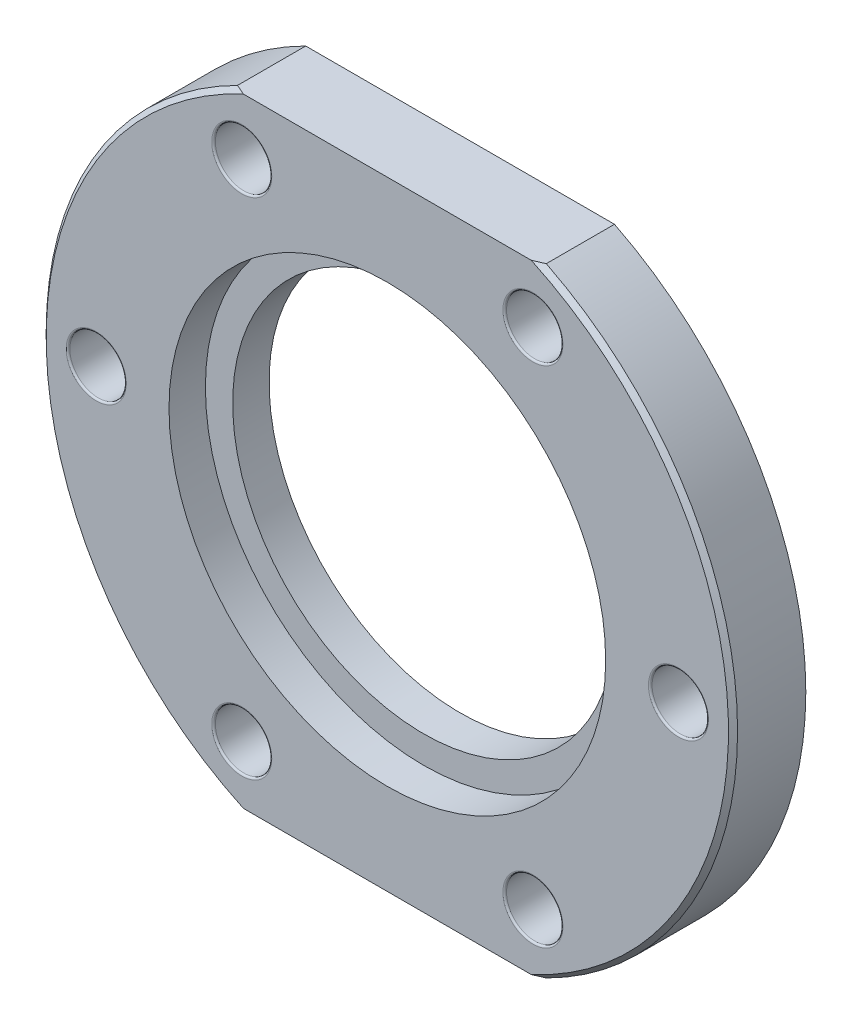
from build123d import *

# Parameters (mm, degrees)
SKETCH1_R               = 19
BOSS_EXTRUDE1_DEPTH     = 4
CUT_EXTRUDE1_DEPTH      = 1
CUT_EXTRUDE1_DEPTH_BACK = 5
SKETCH3_R               = 1.55
CUT_EXTRUDE2_DEPTH      = 1
CUT_EXTRUDE2_DEPTH_BACK = 5
FILLET1_R               = 0.1
SKETCH4_R               = 12
CUT_EXTRUDE3_DEPTH      = 1
CUT_EXTRUDE3_DEPTH_BACK = 2
SKETCH5_R               = 10.5
CUT_EXTRUDE4_DEPTH      = 2
CHAMFER2_SIZE           = 0.25


with BuildPart() as part:
    # Sketch1 → Boss-Extrude1 (new body)
    with BuildSketch(Plane.XY):
        Circle(SKETCH1_R)
    extrude(amount=BOSS_EXTRUDE1_DEPTH)

    # Sketch2 → Cut-Extrude1 (cut, two sides)
    with BuildSketch(Plane.XY.offset(4)) as cut_extrude1_sk:
        with BuildLine():
            Line((8.485281374, -17), (-8.485281374, -17))
            ThreePointArc((-8.485281374, -17), (0, -19), (8.485281374, -17))
        make_face()
        with BuildLine():
            ThreePointArc((-6.7e-08, 19), (-4.358898976, 18.493242001), (-8.485281374, 17))
            Line((-8.485281374, 17), (8.485281374, 17))
            ThreePointArc((8.485281374, 17), (4.358898911, 18.493242017), (-6.7e-08, 19))
        make_face()
    extrude(amount=CUT_EXTRUDE1_DEPTH, mode=Mode.SUBTRACT)
    extrude(cut_extrude1_sk.sketch, amount=-CUT_EXTRUDE1_DEPTH_BACK, mode=Mode.SUBTRACT)

    # Sketch3 → Cut-Extrude2 (cut, two sides)
    with BuildSketch(Plane.XY.offset(4)) as cut_extrude2_sk:
        with Locations((-16, 0)):
            Circle(SKETCH3_R)
        with Locations((-8, 13.856406461)):
            Circle(SKETCH3_R)
        with Locations((8, 13.856406461)):
            Circle(SKETCH3_R)
        with Locations((16, 0)):
            Circle(SKETCH3_R)
        with Locations((8, -13.856406461)):
            Circle(SKETCH3_R)
        with Locations((-8, -13.856406461)):
            Circle(SKETCH3_R)
    extrude(amount=CUT_EXTRUDE2_DEPTH, mode=Mode.SUBTRACT)
    extrude(cut_extrude2_sk.sketch, amount=-CUT_EXTRUDE2_DEPTH_BACK, mode=Mode.SUBTRACT)

    # Fillet1
    fillet1_edges = [part.edges().sort_by_distance(p)[0] for p in [
        (-17.55, 0, 4),
        (-17.55, 0, 0),
        (-9.55, -13.856406461, 4),
        (-9.55, -13.856406461, 0),
        (6.45, -13.856406461, 4),
        (6.45, -13.856406461, 0),
        (14.45, 0, 4),
        (14.45, 0, 0),
        (6.45, 13.856406461, 4),
        (6.45, 13.856406461, 0),
        (-9.55, 13.856406461, 4),
        (-9.55, 13.856406461, 0),
    ]]
    fillet(fillet1_edges, radius=FILLET1_R)

    # Sketch4 → Cut-Extrude3 (cut, two sides)
    with BuildSketch(Plane.XY.offset(4)) as cut_extrude3_sk:
        Circle(SKETCH4_R)
    extrude(amount=CUT_EXTRUDE3_DEPTH, mode=Mode.SUBTRACT)
    extrude(cut_extrude3_sk.sketch, amount=-CUT_EXTRUDE3_DEPTH_BACK, mode=Mode.SUBTRACT)

    # Sketch5 → Cut-Extrude4 (cut)
    with BuildSketch(Plane.XY.offset(2)):
        Circle(SKETCH5_R)
    extrude(amount=-CUT_EXTRUDE4_DEPTH, mode=Mode.SUBTRACT)

    # Chamfer2
    chamfer2_edges = [part.edges().sort_by_distance(p)[0] for p in [
        (-19, 0, 4),
        (19, 0, 4),
    ]]
    chamfer(chamfer2_edges, length=CHAMFER2_SIZE)


solid = part.part
